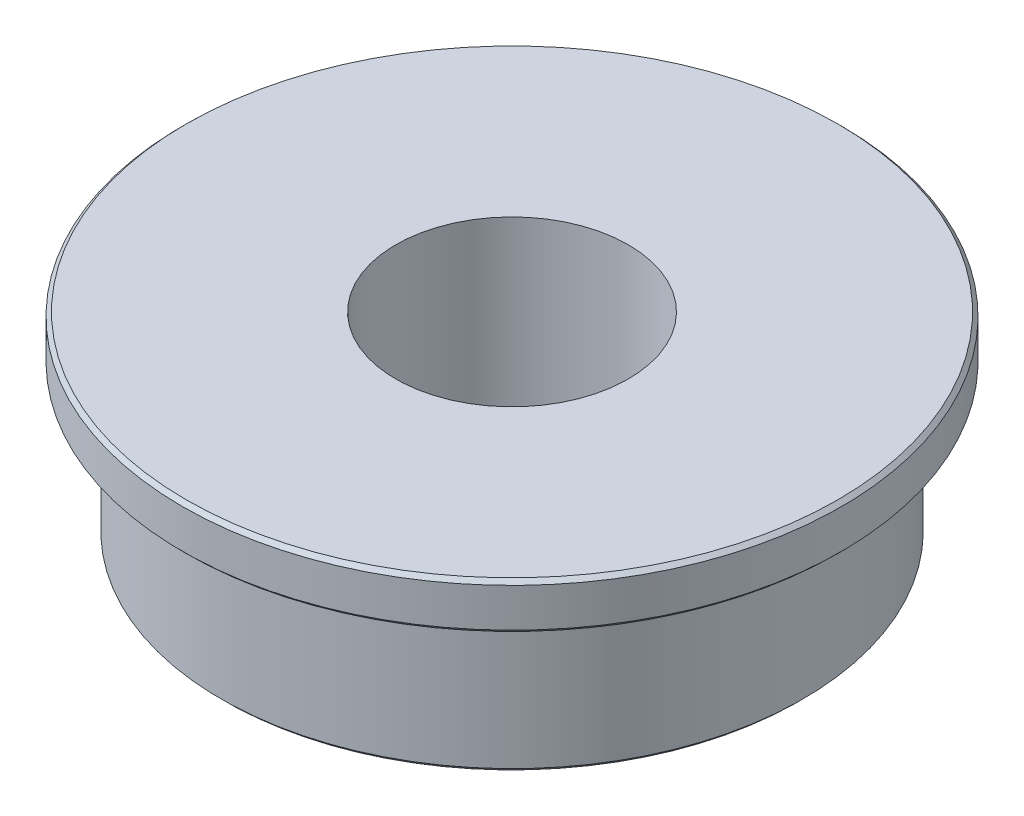
from build123d import *

# Parameters (mm, degrees)
CHAMFER_1_SIZE = 0.1


with BuildPart() as part:
    # 草图1 → 旋转1 (revolve)
    with BuildSketch(Plane.XY):
        Polygon((3, 0), (3, 5), (8.5, 5), (8.5, 3.8), (7.5, 3.8), (7.5, 0), align=None)
    revolve(axis=Axis((0, 0, 0), (0, 1, 0)))

    # 倒角1
    chamfer_1_edges = [part.edges().sort_by_distance(p)[0] for p in [
        (-7.5, 0, 0),
        (-8.5, 3.8, 0),
        (-8.5, 5, 0),
    ]]
    chamfer(chamfer_1_edges, length=CHAMFER_1_SIZE)


solid = part.part
